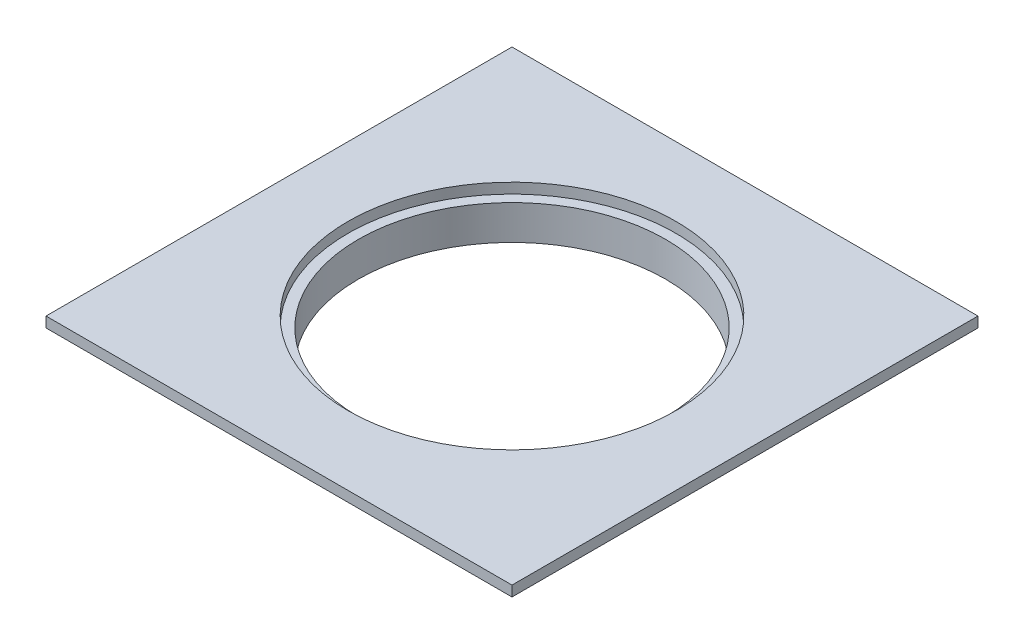
from build123d import *

# Parameters (mm, degrees)
SKETCH1_W           = 135
SKETCH1_H           = 135
SKETCH1_R           = 47.5
BOSS_EXTRUDE1_DEPTH = 3
SKETCH2_R           = 55
SKETCH2_R_2         = 44.5
BOSS_EXTRUDE2_DEPTH = 10


with BuildPart() as part:
    # Sketch1 → Boss-Extrude1 (new body)
    with BuildSketch(Plane(origin=(0, 0, 0), x_dir=(1, 0, 0), z_dir=(0, 1, 0))):
        Rectangle(SKETCH1_W, SKETCH1_H)
        Circle(SKETCH1_R, mode=Mode.SUBTRACT)
    extrude(amount=BOSS_EXTRUDE1_DEPTH)

    # Sketch2 → Boss-Extrude2 (add)
    with BuildSketch(Plane.XZ):
        Circle(SKETCH2_R)
        Circle(SKETCH2_R_2, mode=Mode.SUBTRACT)
    extrude(amount=BOSS_EXTRUDE2_DEPTH)


solid = part.part
